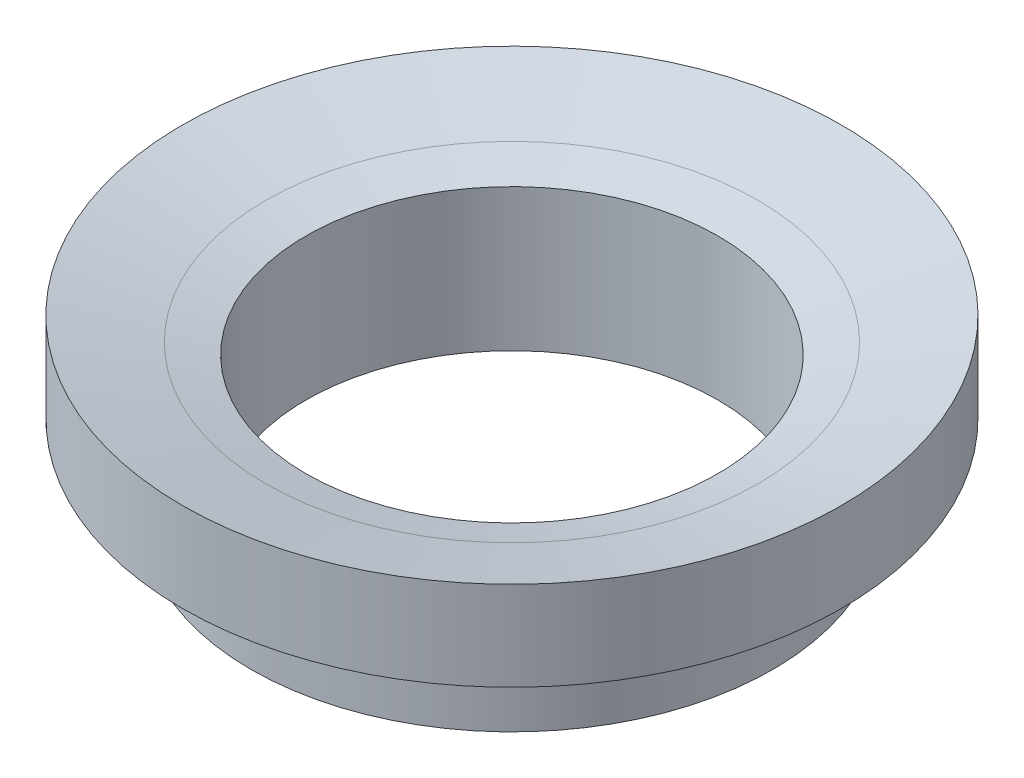
from build123d import *


with BuildPart() as part:
    # Sketch1 → Revolve1 (revolve)
    with BuildSketch(Plane(origin=(0, 0, 0), x_dir=(0, 0, -1), z_dir=(1, 0, 0))):
        with BuildLine():
            Line((-15, 0), (-15, -10.35))
            Line((-15, -10.35), (-19, -10.35))
            Line((-19, -10.35), (-19, -4))
            Line((-19, -4), (-24, -4))
            Line((-24, -4), (-24, 2.493733733))
            Line((-24, 2.493733733), (-17.9, 0.8018))
            add(Edge.make_bspline(
                [(-15, 0), (-15.033336467, 0.009188668), (-15.100017964, 0.027568365), (-15.199979517, 0.055340747), (-15.300021158, 0.082856812), (-15.399978661, 0.110643842), (-15.500021387, 0.138155983), (-15.5999786, 0.165944064), (-15.700021404, 0.193455923), (-15.799978595, 0.22124408), (-15.900021405, 0.24875592), (-15.999978596, 0.276544077), (-16.1000214, 0.304055936), (-16.199978613, 0.331844017), (-16.300021339, 0.359356158), (-16.399978842, 0.387143188), (-16.500020483, 0.414659253), (-16.599982036, 0.442431635), (-16.7, 0.47), (-16.800017964, 0.497568365), (-16.899979517, 0.525340747), (-17.000021158, 0.552856812), (-17.099978661, 0.580643841), (-17.200021386, 0.608155987), (-17.299978604, 0.635944047), (-17.400021386, 0.663455987), (-17.499978661, 0.691243841), (-17.600021158, 0.718756812), (-17.699979517, 0.746540746), (-17.800017964, 0.774068364), (-17.866669801, 0.79255533), (-17.9, 0.8018)],
                knots=[0, 0, 0, 0, 0.034478483, 0.068965823, 0.103444305, 0.137931645, 0.172410128, 0.206897468, 0.241375951, 0.275863291, 0.310341773, 0.344829113, 0.379307596, 0.413794936, 0.448273419, 0.482760759, 0.517239241, 0.551726581, 0.586205064, 0.620683547, 0.655170887, 0.689649369, 0.724136709, 0.758615192, 0.793102532, 0.827581015, 0.862068355, 0.896546837, 0.931034177, 0.96551266, 1, 1, 1, 1], degree=3))
        make_face()
    revolve(axis=Axis((0, 0, 0), (0, -1, 0)))


solid = part.part
